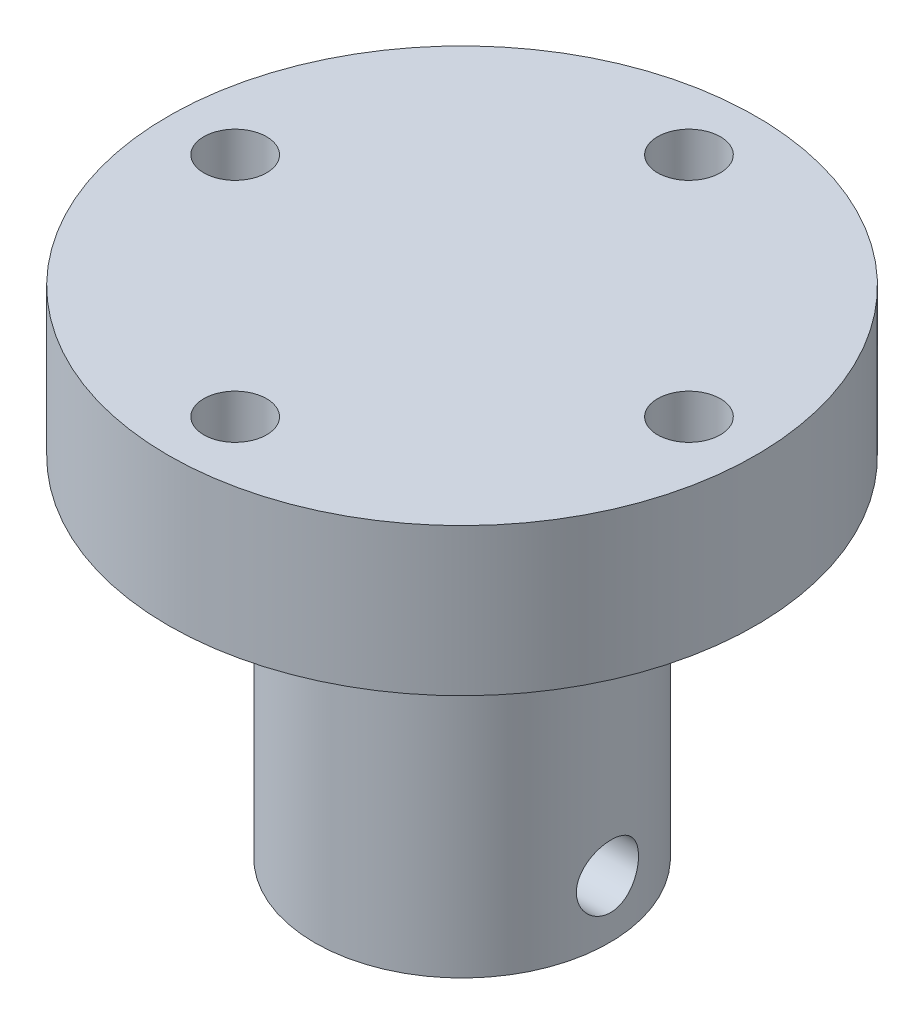
from build123d import *

# Parameters (mm, degrees)
SKETCH1_R                 = 6.35
BOSS_EXTRUDE1_DEPTH       = 15
SKETCH2_R                 = 3.1
CUT_EXTRUDE1_DEPTH        = 10
SKETCH3_R                 = 4.1
CUT_EXTRUDE2_DEPTH        = 5
F_6_32_TAPPED_HOLE1_D     = 2.7051
F_6_32_TAPPED_HOLE1_DEPTH = 7
F_6_32_TAPPED_HOLE1_TIP   = 0.81269403
F_6_32_TAPPED_HOLE2_D     = 2.7051
SKETCH14_R                = 12.660953714
BOSS_EXTRUDE2_DEPTH       = 6.35
F_6_32_TAPPED_HOLE3_D     = 2.7051


with BuildPart() as part:
    # Sketch1 → Boss-Extrude1 (new body)
    with BuildSketch(Plane(origin=(0, 0, 0), x_dir=(0, 0, -1), z_dir=(0, -1, 0))):
        Circle(SKETCH1_R)
    extrude(amount=BOSS_EXTRUDE1_DEPTH)

    # Sketch2 → Cut-Extrude1 (cut)
    with BuildSketch(Plane(origin=(0, 0, 0), x_dir=(1, 0, 0), z_dir=(0, 1, 0))):
        Circle(SKETCH2_R)
    extrude(amount=-CUT_EXTRUDE1_DEPTH, mode=Mode.SUBTRACT)

    # Sketch3 → Cut-Extrude2 (cut)
    with BuildSketch(Plane.XZ.offset(15)):
        Circle(SKETCH3_R)
    extrude(amount=-CUT_EXTRUDE2_DEPTH, mode=Mode.SUBTRACT)

    # #6-32 Tapped Hole1
    with Locations(Plane(origin=(-6.349702391, -3.685069286, 0.061478042), x_dir=(-0.009681581, 0, -0.999953132), z_dir=(-0.999953132, 0, 0.009681581))):
        with Locations((0, 0)):
            Hole(F_6_32_TAPPED_HOLE1_D / 2, depth=F_6_32_TAPPED_HOLE1_DEPTH)
            with Locations((0, 0, -(F_6_32_TAPPED_HOLE1_DEPTH + F_6_32_TAPPED_HOLE1_TIP / 2))):  # 118° drill point
                Cone(0, F_6_32_TAPPED_HOLE1_D / 2, F_6_32_TAPPED_HOLE1_TIP, mode=Mode.SUBTRACT)

    # #6-32 Tapped Hole2 (through all)
    with Locations(Plane(origin=(-6.349688123, -12.545322132, 0.062934409), x_dir=(-0.009910931, 0, -0.999950886), z_dir=(-0.999950886, 0, 0.009910931))):
        with Locations((0, 0)):
            Hole(F_6_32_TAPPED_HOLE2_D / 2)

    # Sketch14 → Boss-Extrude2 (add)
    with BuildSketch(Plane(origin=(0, 0, 0), x_dir=(1, 0, 0), z_dir=(0, 1, 0))):
        Circle(SKETCH14_R)
    extrude(amount=BOSS_EXTRUDE2_DEPTH)

    # #6-32 Tapped Hole3 (through all)
    with Locations(Plane(origin=(0, 0, 0), x_dir=(-1, 0, 0), z_dir=(0, -1, 0))):
        with Locations((-9.779, 0), (0, 9.779), (9.779, 0), (0, -9.779)):
            Hole(F_6_32_TAPPED_HOLE3_D / 2)


solid = part.part
